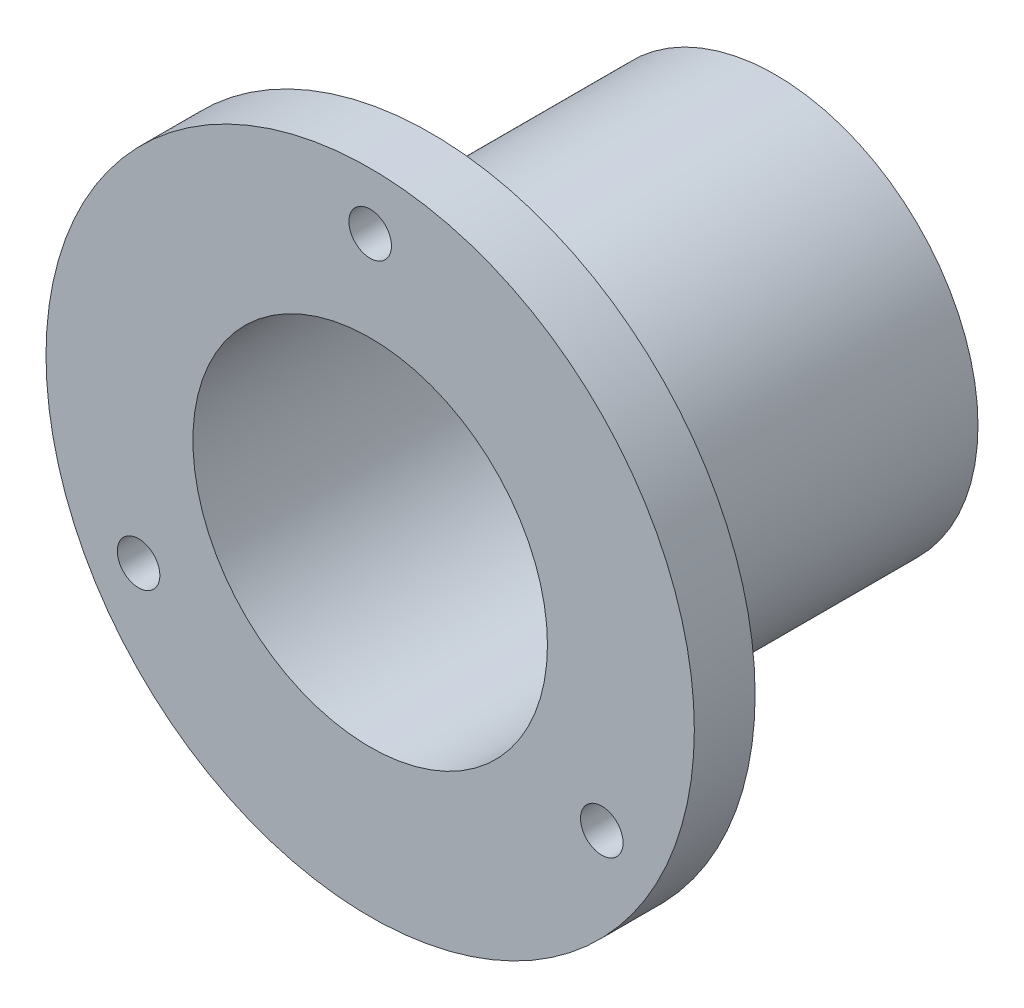
from build123d import *

# Parameters (mm, degrees)
SKETCH1_R           = 20
SKETCH1_R_2         = 17.5
BOSS_EXTRUDE1_DEPTH = 20
SKETCH2_R           = 32
SKETCH2_R_2         = 20
BOSS_EXTRUDE2_DEPTH = 6
SKETCH4_W           = 2.1
SKETCH4_H           = 6
CIRPATTERN1_COUNT   = 3
CHAMFER1_SIZE       = 1
FILLET3_R           = 1


with BuildPart() as part:
    # Sketch1 → Boss-Extrude1 (new body, symmetric)
    with BuildSketch(Plane.XY):
        Circle(SKETCH1_R)
        Circle(SKETCH1_R_2, mode=Mode.SUBTRACT)
    extrude(amount=BOSS_EXTRUDE1_DEPTH, both=True)

    # Chamfer1
    chamfer1_edges = [part.edges().sort_by_distance(p)[0] for p in [
        (-17.5, 0, -20),
    ]]
    chamfer(chamfer1_edges, length=CHAMFER1_SIZE)


with BuildPart() as body_2:
    # Sketch2 → Boss-Extrude2 (new body)
    with BuildSketch(Plane.XY.offset(20)):
        Circle(SKETCH2_R)
        Circle(SKETCH2_R_2, mode=Mode.SUBTRACT)
    extrude(amount=-BOSS_EXTRUDE2_DEPTH)

    # Sketch4 → M5 Tapped Hole1 (revolve, cut)
    with BuildSketch(Plane(origin=(0, 26.4, 14), x_dir=(0, 1, 0), z_dir=(1, 0, 0))):
        with Locations((1.05, 3)):
            Rectangle(SKETCH4_W, SKETCH4_H)
    m5_tapped_hole1 = revolve(axis=Axis((0, 26.4, 7.65), (0, 0, 1)), mode=Mode.SUBTRACT)

    # CirPattern1: M5 Tapped Hole1 ×3 about axis
    cirpattern1_axis = Axis((0, 0, 0), (0, 0, 1))
    for i in range(1, CIRPATTERN1_COUNT):
        add(m5_tapped_hole1.rotate(cirpattern1_axis, i * 360 / CIRPATTERN1_COUNT), mode=Mode.SUBTRACT)


with BuildPart() as part_1:
    add(part.part)

    # Combine1: union body 2
    add(body_2.part)

    # Fillet3
    fillet3_edges = [part_1.edges().sort_by_distance(p)[0] for p in [
        (-20, 0, 14),
    ]]
    fillet(fillet3_edges, radius=FILLET3_R)


solid = part_1.part
